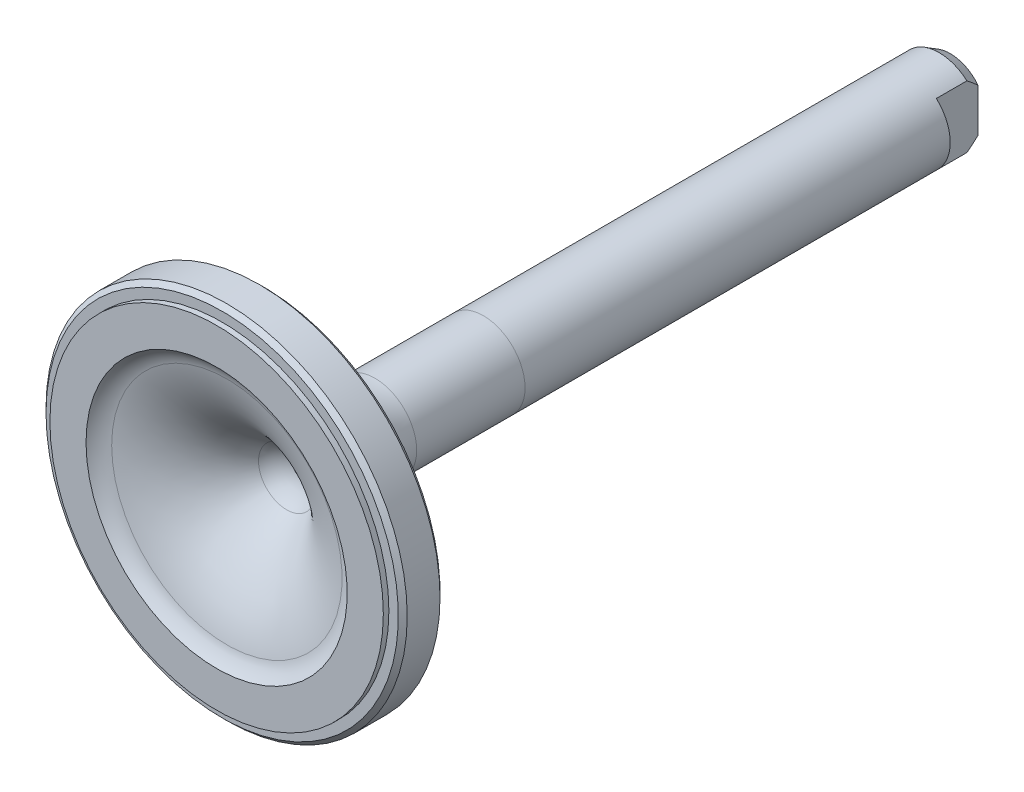
from build123d import *

# Parameters (mm, degrees)
SKETCH1_R           = 41.275
BASE_EXTRUDE_DEPTH  = 10.795
SKETCH6_R           = 9.525
BOSS_EXTRUDE2_DEPTH = 156.845
FILLET1_R           = 25.4
CUT_EXTRUDE2_START  = -4.7625
SKETCH9_R           = 3.3734375
CUT_EXTRUDE2_DEPTH  = 162.6075
SKETCH26_R          = 69.037542482
SKETCH26_R_2        = 38.1
CUT_EXTRUDE7_DEPTH  = 1.27
SKETCH19_W          = 6.35
SKETCH19_H          = 9.525
CUT_EXTRUDE6_DEPTH  = 42.275


with BuildPart() as part:
    # Sketch1 → Base-Extrude (new body)
    with BuildSketch(Plane.XY):
        Circle(SKETCH1_R)
    extrude(amount=BASE_EXTRUDE_DEPTH)

    # Sketch6 → Boss-Extrude2 (add)
    with BuildSketch(Plane(origin=(0, 0, 0), x_dir=(-1, 0, 0), z_dir=(0, 0, -1))):
        with Locations(Location((0, 0, 0), (0, 0, 180))):  # turned: the seam where the file's is
            Circle(SKETCH6_R)
    extrude(amount=BOSS_EXTRUDE2_DEPTH)

    # Fillet1
    fillet1_edges = [part.edges().sort_by_distance(p)[0] for p in [
        (-9.525, 0, 0),
    ]]
    fillet(fillet1_edges, radius=FILLET1_R)

    # Sketch9 → Cut-Extrude2 (cut)
    with BuildSketch(Plane(origin=(0, 0, 0), x_dir=(-1, 0, 0), z_dir=(0, 0, -1)).offset(CUT_EXTRUDE2_START)):
        with Locations((34.925, 0)):
            Circle(SKETCH9_R)
    cut_extrude2 = extrude(amount=CUT_EXTRUDE2_DEPTH, mode=Mode.SUBTRACT)

    # Mirror1: Cut-Extrude2 across plane
    add(cut_extrude2.mirror(Plane(origin=(0, 0, 0), x_dir=(0, 0, 1), z_dir=(1, 0, 0))), mode=Mode.SUBTRACT)

    # Sketch26 → Cut-Extrude7 (cut)
    with BuildSketch(Plane.XY.offset(10.795)):
        Circle(SKETCH26_R)
        Circle(SKETCH26_R_2, mode=Mode.SUBTRACT)
    extrude(amount=-CUT_EXTRUDE7_DEPTH, mode=Mode.SUBTRACT)

    # Sketch19 → Cut-Extrude6 (cut, symmetric)
    with BuildSketch(Plane(origin=(0, 0, 0), x_dir=(1, 0, 0), z_dir=(0, 1, 0))):
        with Locations((9.525, 152.0825)):
            Rectangle(SKETCH19_W, SKETCH19_H)
    cut_extrude6 = extrude(amount=CUT_EXTRUDE6_DEPTH, both=True, mode=Mode.SUBTRACT)

    # Mirror2: Cut-Extrude6 across plane
    add(cut_extrude6.mirror(Plane(origin=(0, 0, 0), x_dir=(0, 0, 1), z_dir=(1, 0, 0))), mode=Mode.SUBTRACT)

    # Sketch21 → Cut-Revolve6 (revolve, cut)
    with BuildSketch(Plane(origin=(0, 0, 0), x_dir=(1, 0, 0), z_dir=(0, 1, 0))):
        with BuildLine():
            Line((29.845, -10.795), (0, -10.795))
            Line((0, -10.795), (0, 8.916390985))
            Line((0, 8.916390985), (1.5875, 8.916390985))
            Line((1.5875, 8.916390985), (1.5875, 8.37370061))
            ThreePointArc((1.5875, 8.37370061), (4.306912353, 7.253081359), (6.42537092, 5.212707777))
            ThreePointArc((6.42537092, 5.212707777), (15.158650592, -3.393177249), (26.328076923, -8.450384615))
            ThreePointArc((26.328076923, -8.450384615), (28.287346246, -9.321480631), (29.845, -10.795))
        make_face()
    revolve(axis=Axis((0, 0, 10.795), (0, 0, 1)), mode=Mode.SUBTRACT)

    # Sketch22 → Cut-Revolve7 (revolve, cut)
    with BuildSketch(Plane(origin=(0, 0, 0), x_dir=(1, 0, 0), z_dir=(0, 1, 0))):
        Polygon((8.058530316, 156.845), (9.525, 156.845), (9.525, 154.305), align=None)
    revolve(axis=Axis((0, 0, 10.795), (0, 0, -1)), mode=Mode.SUBTRACT)

    # Sketch23 → Cut-Revolve8 (revolve, cut)
    with BuildSketch(Plane(origin=(0, 0, 0), x_dir=(1, 0, 0), z_dir=(0, 1, 0)), mode=Mode.PRIVATE) as cut_revolve8_sk:
        Polygon((40.259, 0), (41.275, 0), (41.275, -1.016), align=None)
        Polygon((40.259, -9.525), (41.275, -9.525), (41.275, -8.509), align=None)
    revolve(cut_revolve8_sk.sketch.rotate(Axis((0, 0, 10.795), (0, 0, 1)), 180), axis=Axis((0, 0, 10.795), (0, 0, 1)), mode=Mode.SUBTRACT)  # turned: the seam where the file's is


solid = part.part
